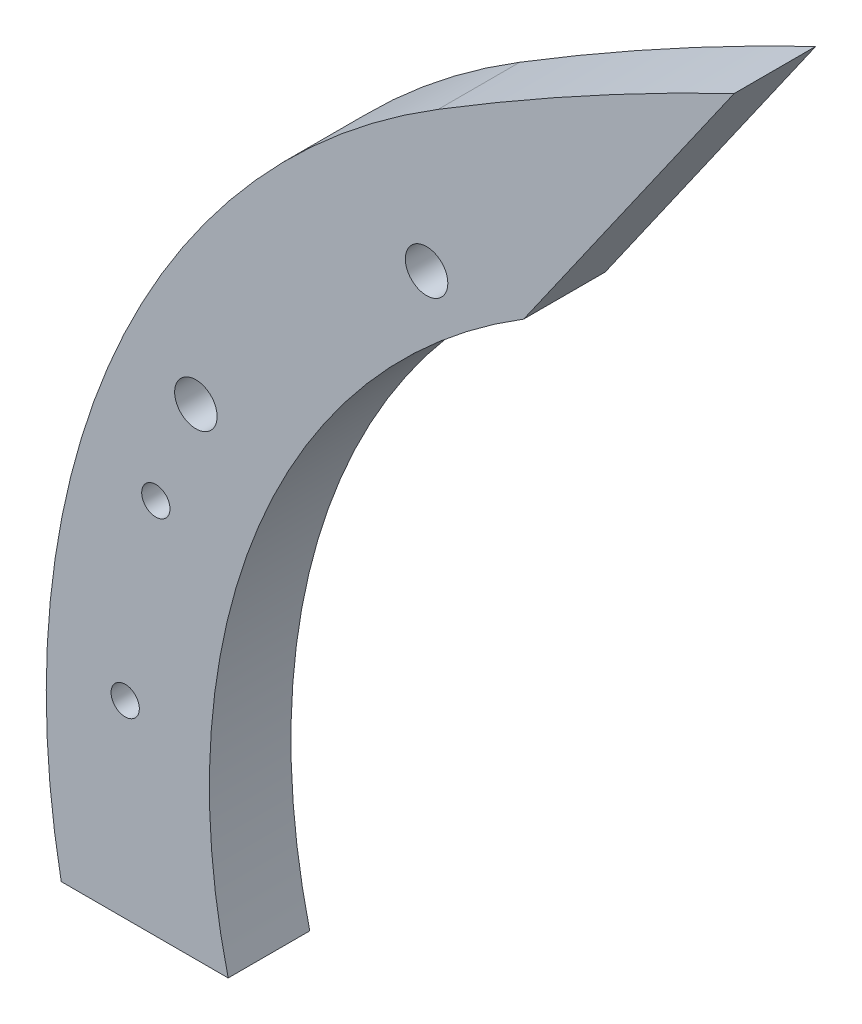
from build123d import *

# Parameters (mm, degrees)
BOSS_EXTRUDE1_DEPTH              = 9.525
SKETCH2_R                        = 3.302
CUT_EXTRUDE1_DEPTH               = 19.05
F_25_64_0_39063_DIAMETER_HOLE1_D = 9.922002


with BuildPart() as part:
    # Sketch1 → Boss-Extrude1 (new body, symmetric)
    with BuildSketch(Plane.XY):
        with BuildLine():
            Line((-80.658868274, 131.257470336), (-31.489028268, 201.479279332))
            ThreePointArc((-31.489028268, 201.479279332), (-66.529224029, 183.480200423), (-100.606355042, 163.718335568))
            ThreePointArc((-100.606355042, 163.718335568), (-175.90250014, 77.354007785), (-188.658870504, -36.5125))
            Line((-188.658870504, -36.5125), (-149.670350751, -36.5125))
            ThreePointArc((-149.670350751, -36.5125), (-142.476587623, 58.607154251), (-80.658868274, 131.257470336))
        make_face()
    extrude(amount=BOSS_EXTRUDE1_DEPTH, both=True)

    # Sketch2 → Cut-Extrude1 (cut)
    with BuildSketch(Plane.XY.offset(9.525)):
        with Locations((-173.718655592, 7.579557452)):
            Circle(SKETCH2_R)
        with Locations((-166.564839951, 51.569288407)):
            Circle(SKETCH2_R)
    extrude(amount=-CUT_EXTRUDE1_DEPTH, mode=Mode.SUBTRACT)

    # 25_64 _0.39063_ Diameter Hole1 (through all)
    with Locations(Plane.XY.offset(9.525)):
        with Locations((-103.331077236, 129.637230364), (-157.212613963, 75.755693637)):
            Hole(F_25_64_0_39063_DIAMETER_HOLE1_D / 2)


solid = part.part
